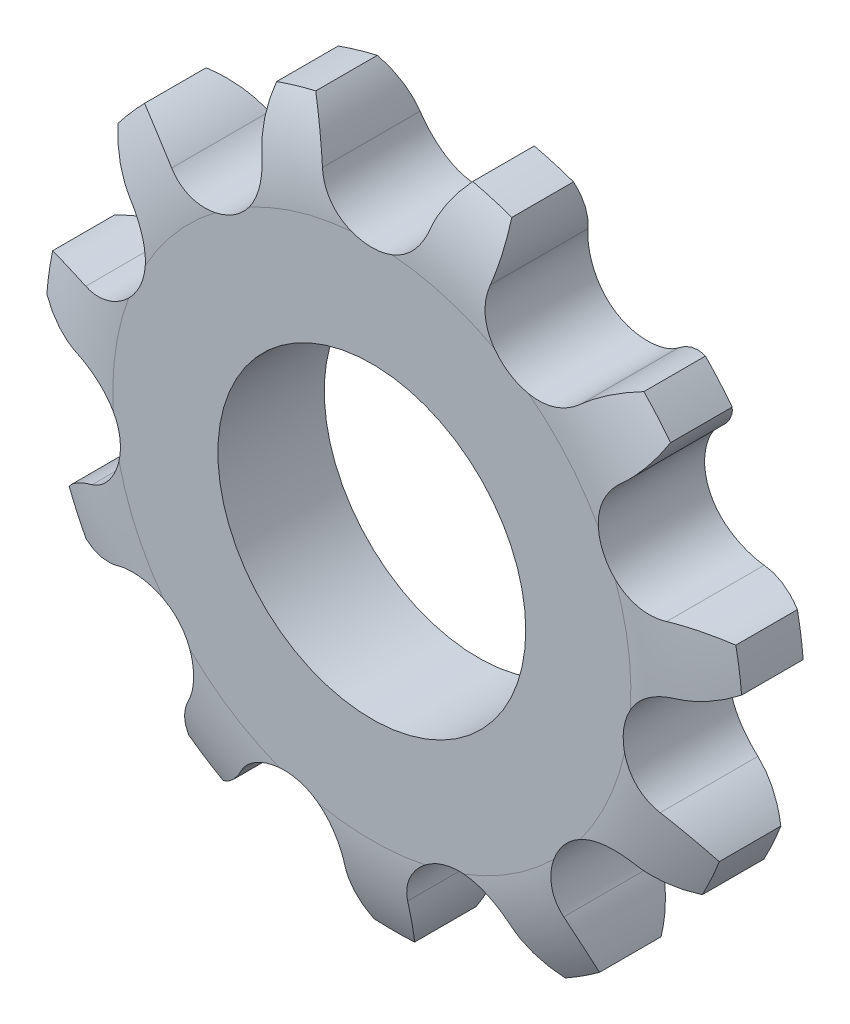
from build123d import *

# Parameters (mm, degrees)
SKETCH1_R           = 31.636392459
BOSS_EXTRUDE1_DEPTH = 4.826
CUT_EXTRUDE4_DEPTH  = 6.35
CIRPATTERN1_COUNT   = 11
SKETCH7_R           = 13.97
CUT_EXTRUDE8_DEPTH  = 46.692454129


with BuildPart() as part:
    # Sketch1 → Boss-Extrude1 (new, symmetric)
    with BuildSketch(Plane.XY):
        Circle(SKETCH1_R)
    extrude(amount=BOSS_EXTRUDE1_DEPTH, both=True)

    # Sketch2 → Cut-Revolve1 (revolve, cut)
    with BuildSketch(Plane(origin=(0, 0, 0), x_dir=(1, 0, 0), z_dir=(0, 1, 0))):
        with BuildLine():
            Line((-31.636392459, -4.826), (-23.508392459, -4.826))
            ThreePointArc((-23.508392459, -4.826), (-27.697467774, -4.310301263), (-31.636392459, -2.794))
            Line((-31.636392459, -2.794), (-31.636392459, -4.826))
        make_face()
    cut_revolve1 = revolve(axis=Axis((0, 0, 4.826), (0, 0, 1)), mode=Mode.SUBTRACT)

    # Mirror1: Cut-Revolve1 across plane
    add(cut_revolve1.mirror(Plane.XY), mode=Mode.SUBTRACT)

    # Sketch3 → Cut-Extrude4 (cut, symmetric)
    with BuildSketch(Plane.XY):
        with BuildLine():
            ThreePointArc((-7.120745292, 30.824605663), (-5.774631469, 28.906292652), (-4.874224306, 26.742681279))
            ThreePointArc((-4.874224306, 26.742681279), (0, 23.093882667), (4.874224306, 26.742681279))
            ThreePointArc((4.874224306, 26.742681279), (5.774631469, 28.906292652), (7.120745292, 30.824605663))
            ThreePointArc((7.120745292, 30.824605663), (0, 31.636392459), (-7.120745292, 30.824605663))
        make_face()
    cut_extrude4 = extrude(amount=CUT_EXTRUDE4_DEPTH, both=True, mode=Mode.SUBTRACT)

    # CirPattern1: Cut-Extrude4 ×11 about axis
    cirpattern1_axis = Axis((0, 0, 0), (0, 0, 1))
    for i in range(1, CIRPATTERN1_COUNT):
        add(cut_extrude4.rotate(cirpattern1_axis, i * 360 / CIRPATTERN1_COUNT), mode=Mode.SUBTRACT)

    # Sketch7 → Cut-Extrude8 (cut, through all)
    with BuildSketch(Plane.XY.offset(4.826)):
        Circle(SKETCH7_R)
    extrude(amount=-CUT_EXTRUDE8_DEPTH, mode=Mode.SUBTRACT)


solid = part.part
